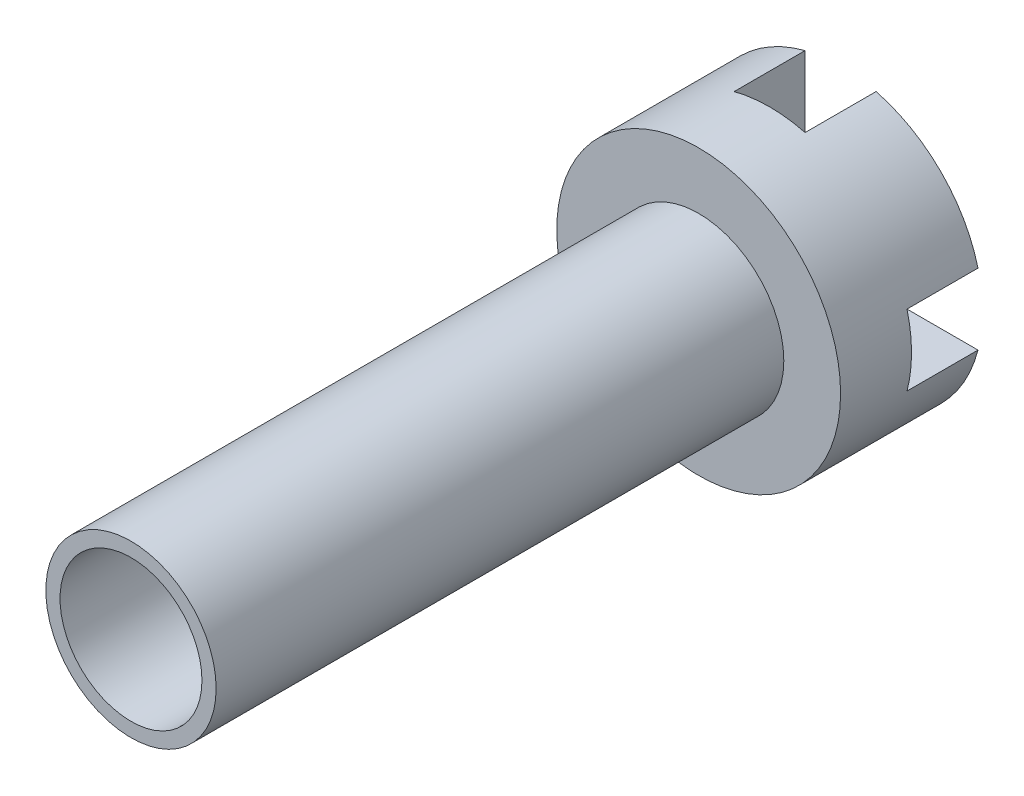
from build123d import *

# Parameters (mm, degrees)
ESQUISSE1_R             = 10
BOSS_EXTRU_1_DEPTH      = 10
ESQUISSE2_R             = 6
BOSS_EXTRU_2_DEPTH      = 40
ESQUISSE3_R             = 5
ENL_V_MAT_EXTRU_1_DEPTH = 30
ESQUISSE5_W             = 5
ESQUISSE5_H             = 5
ENL_V_MAT_EXTRU_2_DEPTH = 5


with BuildPart() as part:
    # Esquisse1 → Boss.-Extru.1 (new body)
    with BuildSketch(Plane.XY):
        Circle(ESQUISSE1_R)
    extrude(amount=BOSS_EXTRU_1_DEPTH)

    # Esquisse2 → Boss.-Extru.2 (add)
    with BuildSketch(Plane.XY.offset(10)):
        Circle(ESQUISSE2_R)
    extrude(amount=BOSS_EXTRU_2_DEPTH)

    # Esquisse3 → Enlèv. mat.-Extru.1 (cut)
    with BuildSketch(Plane.XY.offset(50)):
        Circle(ESQUISSE3_R)
    extrude(amount=-ENL_V_MAT_EXTRU_1_DEPTH, mode=Mode.SUBTRACT)

    # Esquisse5 → Enlèv. mat.-Extru.2 (cut)
    with BuildSketch(Plane(origin=(0, 0, 0), x_dir=(-1, 0, 0), z_dir=(0, 0, -1))):
        with BuildLine():
            Line((-2.5, 9.682458366), (-2.5, 2.5))
            Line((-2.5, 2.5), (2.5, 2.5))
            Line((2.5, 2.5), (2.5, 9.682458366))
            ThreePointArc((2.5, 9.682458366), (1.260042925, 9.920296963), (0, 10))
            ThreePointArc((0, 10), (-1.260042925, 9.920296963), (-2.5, 9.682458366))
        make_face()
        with BuildLine():
            Line((-2.5, 2.5), (-9.682458366, 2.5))
            ThreePointArc((-9.682458366, 2.5), (-9.920296963, 1.260042925), (-10, 0))
            ThreePointArc((-10, 0), (-9.920296963, -1.260042925), (-9.682458366, -2.5))
            Line((-9.682458366, -2.5), (-2.5, -2.5))
            Line((-2.5, -2.5), (-2.5, 2.5))
        make_face()
        Rectangle(ESQUISSE5_W, ESQUISSE5_H)
        with BuildLine():
            Line((9.682458366, 2.5), (2.5, 2.5))
            Line((2.5, 2.5), (2.5, -2.5))
            Line((2.5, -2.5), (9.682458366, -2.5))
            ThreePointArc((9.682458366, -2.5), (9.920296963, -1.260042925), (10, 0))
            ThreePointArc((10, 0), (9.920296963, 1.260042925), (9.682458366, 2.5))
        make_face()
        with BuildLine():
            Line((2.5, -2.5), (-2.5, -2.5))
            Line((-2.5, -2.5), (-2.5, -9.682458366))
            ThreePointArc((-2.5, -9.682458366), (-1.260042925, -9.920296963), (0, -10))
            ThreePointArc((0, -10), (1.260042925, -9.920296963), (2.5, -9.682458366))
            Line((2.5, -9.682458366), (2.5, -2.5))
        make_face()
    extrude(amount=-ENL_V_MAT_EXTRU_2_DEPTH, mode=Mode.SUBTRACT)


solid = part.part
